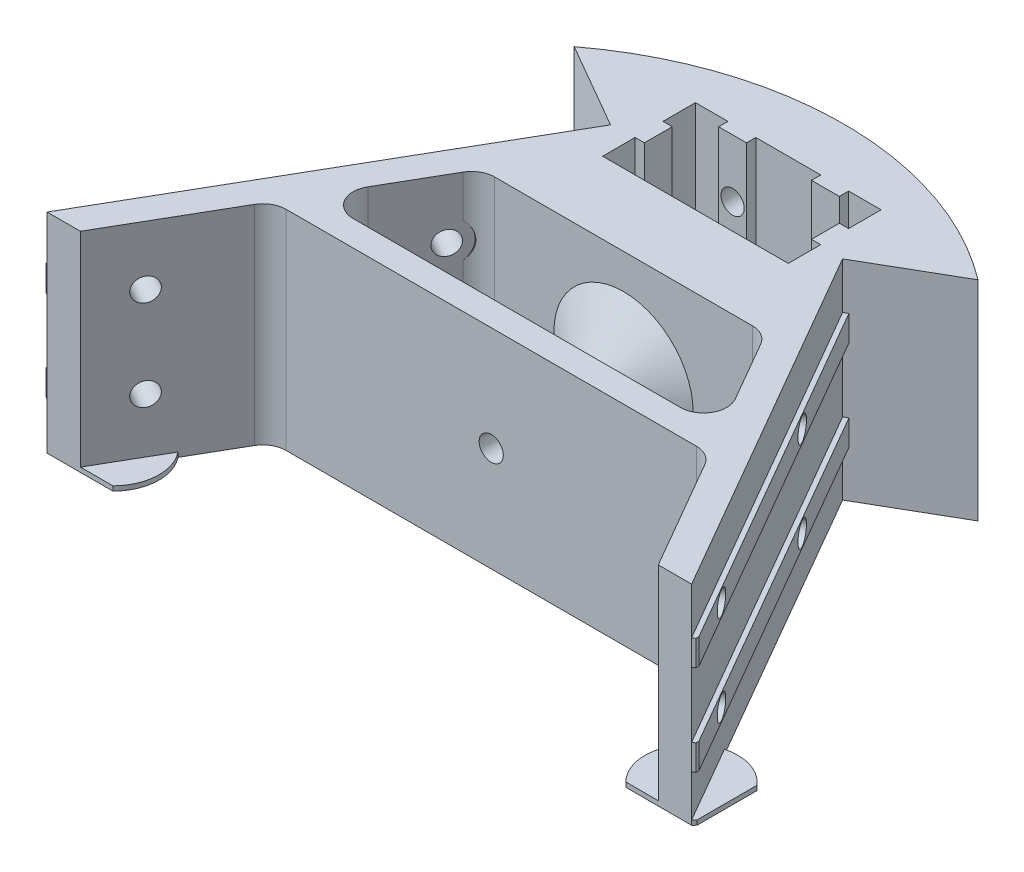
from build123d import *

# Parameters (mm, degrees)
BOSS_EXTRUDE1_DEPTH = 45
SKETCH3_W           = 92.200496998
SKETCH3_H           = 5.5
BOSS_EXTRUDE2_DEPTH = 1
SKETCH4_R           = 2.5
CUT_EXTRUDE2_DEPTH  = 7.222605
SKETCH8_R           = 4.5
CUT_EXTRUDE7_DEPTH  = 0.386255
CUT_EXTRUDE3_START  = -13.60831
SKETCH5_R           = 2.5
CUT_EXTRUDE3_DEPTH  = 13.60831
CUT_EXTRUDE5_START  = -14
SKETCH6_R           = 4.25
CUT_EXTRUDE5_DEPTH  = 1.7
SKETCH10_R          = 2.6
CUT_EXTRUDE8_DEPTH  = 32
SKETCH11_R          = 10
BOSS_EXTRUDE3_DEPTH = 1
CUT_EXTRUDE10_DEPTH = 46.0000001


with BuildPart() as part:
    # Sketch1 → Boss-Extrude1 (new body)
    with BuildSketch(Plane(origin=(0, 0, 0), x_dir=(1, 0, 0), z_dir=(0, 1, 0))):
        with BuildLine():
            Line((67.073634163, -66.174942219), (25, 6.698729811))
            Line((25, 6.698729811), (43.49555567, 17.377143855))
            ThreePointArc((43.49555567, 17.377143855), (0, 32), (-43.49555567, 17.377143855))
            Line((-43.49555567, 17.377143855), (-25, 6.698729811))
            Line((-25, 6.698729811), (-67.073634163, -66.174942219))
            Line((-67.073634163, -66.174942219), (-71.100248499, -73.149242831))
            Line((-71.100248499, -73.149242831), (-63.915003714, -73.149242831))
            Line((-63.915003714, -73.149242831), (-48.529056191, -46.5))
            ThreePointArc((-48.529056191, -46.5), (-46.698929172, -44.669872981), (-44.198929172, -44))
            Line((-44.198929172, -44), (44.198929172, -44))
            ThreePointArc((44.198929172, -44), (46.698929172, -44.669872981), (48.529056191, -46.5))
            Line((48.529056191, -46.5), (63.915003714, -73.149242831))
            Line((63.915003714, -73.149242831), (71.100248499, -73.149242831))
            Line((71.100248499, -73.149242831), (67.073634163, -66.174942219))
        make_face()
        Polygon((-20, 20), (-13, 20), (-13, 18), (-7, 18), (-7, 20), (7, 20), (7, 18), (13, 18), (13, 20), (20, 20), (20, 13), (18, 13), (18, 7), (20, 7), (20, 0), (-20, 0), (-20, 7), (-18, 7), (-18, 13), (-20, 13), align=None, mode=Mode.SUBTRACT)
        with BuildLine():
            Line((-27.744446501, -15.5), (27.744446501, -15.5))
            ThreePointArc((27.744446501, -15.5), (30.244446501, -16.169872981), (32.074573519, -18))
            Line((32.074573519, -18), (39.580127019, -31))
            ThreePointArc((39.580127019, -31), (39.580127019, -36), (35.25, -38.5))
            Line((35.25, -38.5), (-35.25, -38.5))
            ThreePointArc((-35.25, -38.5), (-39.580127019, -36), (-39.580127019, -31))
            Line((-39.580127019, -31), (-32.074573519, -18))
            ThreePointArc((-32.074573519, -18), (-30.244446501, -16.169872981), (-27.744446501, -15.5))
        make_face(mode=Mode.SUBTRACT)
    extrude(amount=BOSS_EXTRUDE1_DEPTH)

    # Sketch3 → Boss-Extrude2 (add)
    with BuildSketch(Plane(origin=(21.650635095, 0, -12.5), x_dir=(-0.5, 0, -0.866025404), z_dir=(0.866025404, 0, -0.5))):
        with Locations((-52.79897831, 32.25)):
            Rectangle(SKETCH3_W, SKETCH3_H)
        with Locations((-52.79897831, 12.75)):
            Rectangle(SKETCH3_W, SKETCH3_H)
    boss_extrude2 = extrude(amount=BOSS_EXTRUDE2_DEPTH)

    # Sketch4 → Cut-Extrude2 (cut)
    with BuildSketch(Plane(origin=(22.516660498, 0, -13), x_dir=(-0.5, 0, -0.866025404), z_dir=(0.866025404, 0, -0.5))):
        with Locations((-34.198729811, 32.25)):
            Circle(SKETCH4_R)
        with Locations((-34.198729811, 12.75)):
            Circle(SKETCH4_R)
        with Locations((-81.698729811, 12.75)):
            Circle(SKETCH4_R)
        with Locations((-81.698729811, 32.25)):
            Circle(SKETCH4_R)
    cut_extrude2 = extrude(amount=-CUT_EXTRUDE2_DEPTH, mode=Mode.SUBTRACT)

    # Sketch8 → Cut-Extrude7 (cut)
    with BuildSketch(Plane(origin=(16.261701506, 0, -9.388697742), x_dir=(0.5, 0, 0.866025404), z_dir=(-0.866025404, 0, 0.5))):
        with Locations((34.198729811, 32.25)):
            Circle(SKETCH8_R)
        with Locations((34.198729811, 12.75)):
            Circle(SKETCH8_R)
    cut_extrude7 = extrude(amount=CUT_EXTRUDE7_DEPTH, mode=Mode.SUBTRACT)

    # Sketch5 → Cut-Extrude3 (cut)
    with BuildSketch(Plane.XY.offset(-18).offset(CUT_EXTRUDE3_START)):
        with Locations((10, 32.5)):
            Circle(SKETCH5_R)
        with Locations((10, 12.5)):
            Circle(SKETCH5_R)
    cut_extrude3 = extrude(amount=CUT_EXTRUDE3_DEPTH, mode=Mode.SUBTRACT)

    # Sketch6 → Cut-Extrude5 (cut)
    with BuildSketch(Plane.XY.offset(-18).offset(CUT_EXTRUDE5_START)):
        with Locations((10, 32.5)):
            Circle(SKETCH6_R)
        with Locations((10, 12.5)):
            Circle(SKETCH6_R)
    cut_extrude5 = extrude(amount=CUT_EXTRUDE5_DEPTH, mode=Mode.SUBTRACT)

    # Mirror1: Boss-Extrude2, Cut-Extrude2, Cut-Extrude7, Cut-Extrude3, Cut-Extrude5 across plane
    add(boss_extrude2.mirror(Plane(origin=(0, 0, 0), x_dir=(0, 0, 1), z_dir=(1, 0, 0))))
    add(cut_extrude2.mirror(Plane(origin=(0, 0, 0), x_dir=(0, 0, 1), z_dir=(1, 0, 0))), mode=Mode.SUBTRACT)
    add(cut_extrude7.mirror(Plane(origin=(0, 0, 0), x_dir=(0, 0, 1), z_dir=(1, 0, 0))), mode=Mode.SUBTRACT)
    add(cut_extrude3.mirror(Plane(origin=(0, 0, 0), x_dir=(0, 0, 1), z_dir=(1, 0, 0))), mode=Mode.SUBTRACT)
    add(cut_extrude5.mirror(Plane(origin=(0, 0, 0), x_dir=(0, 0, 1), z_dir=(1, 0, 0))), mode=Mode.SUBTRACT)

    # Sketch9 → Revolve1 (revolve)
    with BuildSketch(Plane(origin=(0, 0, 0), x_dir=(0, 0, -1), z_dir=(1, 0, 0))):
        Polygon((-31.1, 26.1), (-31.1, 22.5), (-38.5, 22.5), (-38.5, 37.5), align=None)
        Polygon((-22.9, 26.1), (-15.5, 37.5), (-15.5, 22.5), (-22.9, 22.5), align=None)
    revolve(axis=Axis((0, 22.5, 15.5), (0, 0, 1)))

    # Sketch10 → Cut-Extrude8 (cut)
    with BuildSketch(Plane.XY.offset(44)):
        with Locations((0, 22.5)):
            Circle(SKETCH10_R)
    extrude(amount=-CUT_EXTRUDE8_DEPTH, mode=Mode.SUBTRACT)

    # Sketch11 → Boss-Extrude3 (add)
    with BuildSketch(Plane(origin=(0, 0, 0), x_dir=(1, 0, 0), z_dir=(0, 1, 0))):
        with Locations((62.338794406, -63.196563711)):
            Circle(SKETCH11_R)
        with Locations((-62.338794406, -63.196563711)):
            Circle(SKETCH11_R)
    extrude(amount=BOSS_EXTRUDE3_DEPTH)

    # Sketch14 → Cut-Extrude10 (cut, through all)
    with BuildSketch(Plane(origin=(0, 0, 0), x_dir=(1, 0, 0), z_dir=(0, 1, 0))):
        Polygon((-80, -75.149242831), (80, -75.149242831), (80, -53.149242831), (70, -53.149242831), (70, -69.917804932), (69.425932718, -70.249242831), (-69.425932718, -70.249242831), (-70, -69.917804932), (-70, -53.149242831), (-80, -53.149242831), align=None)
    extrude(amount=CUT_EXTRUDE10_DEPTH, mode=Mode.SUBTRACT)


solid = part.part
